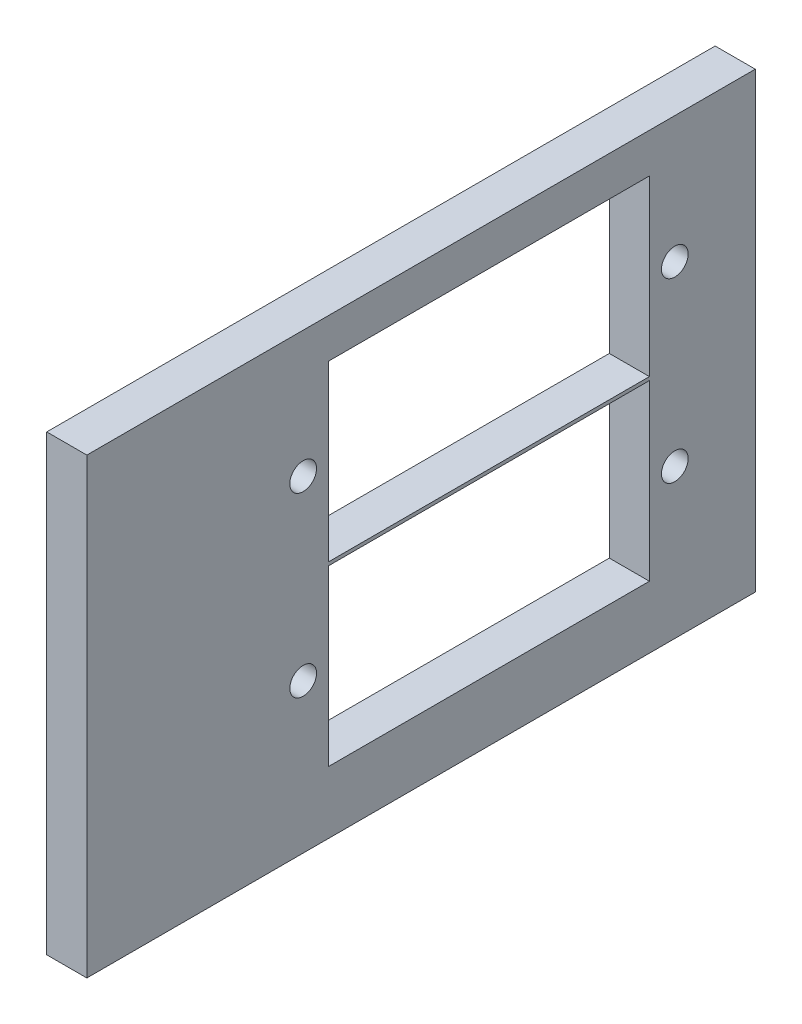
from build123d import *

# Parameters (mm, degrees)
SKETCH1_W           = 50
SKETCH1_H           = 33.876964868
BOSS_EXTRUDE1_DEPTH = 3
SKETCH2_R           = 1
SKETCH2_W           = 24
SKETCH2_H           = 13
CUT_EXTRUDE1_DEPTH  = 4


with BuildPart() as part:
    # Sketch1 → Boss-Extrude1 (new body)
    with BuildSketch(Plane(origin=(0, 0, 0), x_dir=(0, 0, -1), z_dir=(1, 0, 0))):
        with Locations((16.038383019, -39.775181141)):
            Rectangle(SKETCH1_W, SKETCH1_H)
    extrude(amount=BOSS_EXTRUDE1_DEPTH)

    # Sketch2 → Cut-Extrude1 (cut, through all)
    with BuildSketch(Plane.ZY):
        with Locations((-35.020353647, -45.551677475)):
            Circle(SKETCH2_R)
        with Locations((-7.220353647, -45.551677475)):
            Circle(SKETCH2_R)
        with Locations((-35.020353647, -32.293971569)):
            Circle(SKETCH2_R)
        with Locations((-7.220353647, -32.293971569)):
            Circle(SKETCH2_R)
        with Locations((-21.120353647, -45.551677475)):
            Rectangle(SKETCH2_W, SKETCH2_H)
        with Locations((-21.120353647, -32.293971569)):
            Rectangle(SKETCH2_W, SKETCH2_H)
    extrude(amount=-CUT_EXTRUDE1_DEPTH, mode=Mode.SUBTRACT)


solid = part.part
